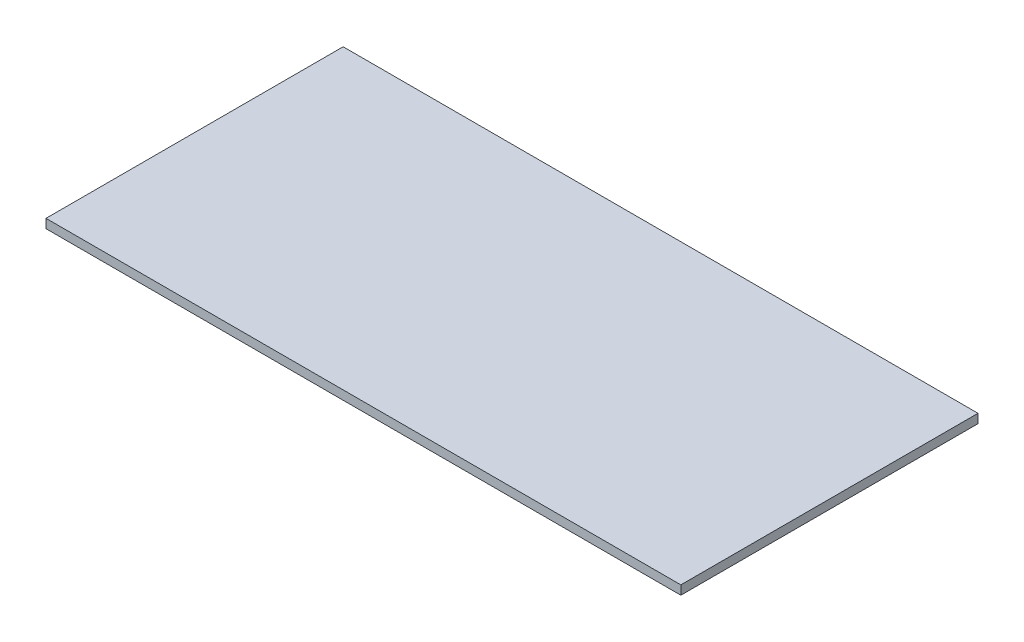
from build123d import *

# Parameters (mm, degrees)
SKETCH1_W           = 1269
SKETCH1_H           = 594
BOSS_EXTRUDE1_DEPTH = 18


with BuildPart() as part:
    # Sketch1 → Boss-Extrude1 (new body)
    with BuildSketch(Plane(origin=(0, 0, 0), x_dir=(1, 0, 0), z_dir=(0, 1, 0))):
        Rectangle(SKETCH1_W, SKETCH1_H)
    extrude(amount=BOSS_EXTRUDE1_DEPTH)


solid = part.part
